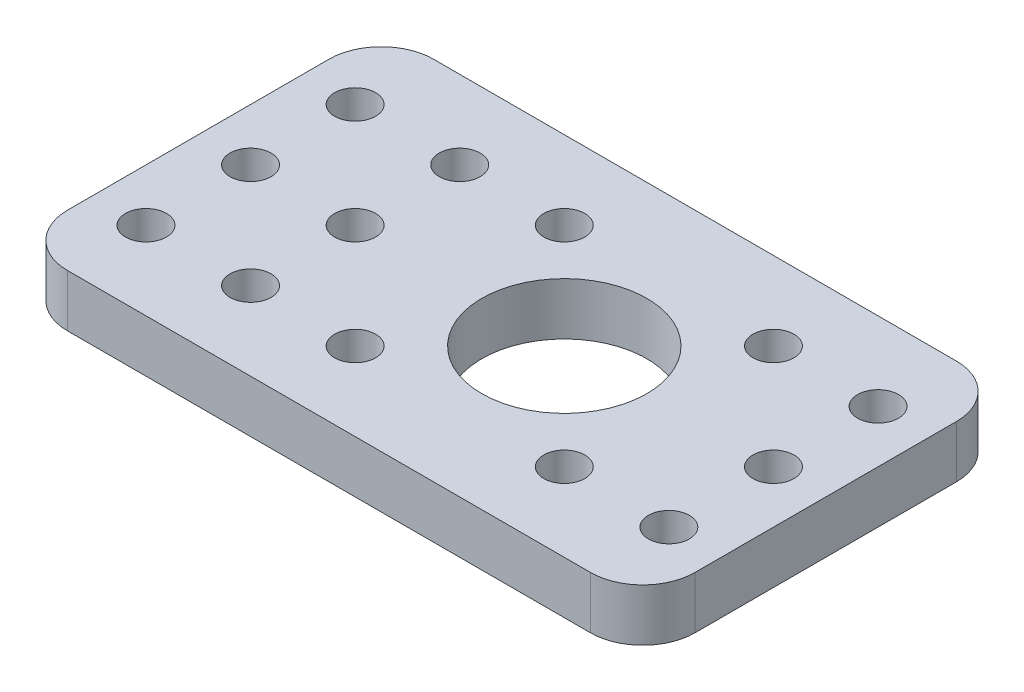
from build123d import *

# Parameters (mm, degrees)
SKETCH1_W           = 76.2
SKETCH1_H           = 44.45
BOSS_EXTRUDE1_DEPTH = 6.35
FILLET1_R           = 6.35
SKETCH2_R           = 2.4892
SKETCH2_R_2         = 10.025399939
CUT_EXTRUDE1_DEPTH  = 7.35


with BuildPart() as part:
    # Sketch1 → Boss-Extrude1 (new body)
    with BuildSketch(Plane(origin=(0, 0, 0), x_dir=(1, 0, 0), z_dir=(0, 1, 0))):
        with Locations((38.1, 22.225)):
            Rectangle(SKETCH1_W, SKETCH1_H)
    extrude(amount=BOSS_EXTRUDE1_DEPTH)

    # Fillet1
    fillet1_edges = [part.edges().sort_by_distance(p)[0] for p in [
        (0, 3.175, -44.45),
        (76.2, 3.175, -44.45),
        (76.2, 3.175, 0),
        (0, 3.175, 0),
    ]]
    fillet(fillet1_edges, radius=FILLET1_R)

    # Sketch2 → Cut-Extrude1 (cut, through all)
    with BuildSketch(Plane(origin=(0, 6.35, 0), x_dir=(1, 0, 0), z_dir=(0, 1, 0))):
        with Locations((31.75, 34.925)):
            Circle(SKETCH2_R)
        with Locations((6.35, 34.925)):
            Circle(SKETCH2_R)
        with Locations((19.05, 34.925)):
            Circle(SKETCH2_R)
        with Locations((19.05, 22.225)):
            Circle(SKETCH2_R)
        with Locations((6.35, 22.225)):
            Circle(SKETCH2_R)
        with Locations((6.35, 9.525)):
            Circle(SKETCH2_R)
        with Locations((19.05, 9.525)):
            Circle(SKETCH2_R)
        with Locations((31.75, 9.525)):
            Circle(SKETCH2_R)
        with Locations((57.15, 9.525)):
            Circle(SKETCH2_R)
        with Locations((69.85, 9.525)):
            Circle(SKETCH2_R)
        with Locations((69.85, 22.225)):
            Circle(SKETCH2_R)
        with Locations((69.85, 34.925)):
            Circle(SKETCH2_R)
        with Locations((57.15, 34.925)):
            Circle(SKETCH2_R)
        with Locations((44.45, 22.225)):
            Circle(SKETCH2_R_2)
    extrude(amount=-CUT_EXTRUDE1_DEPTH, mode=Mode.SUBTRACT)


solid = part.part
